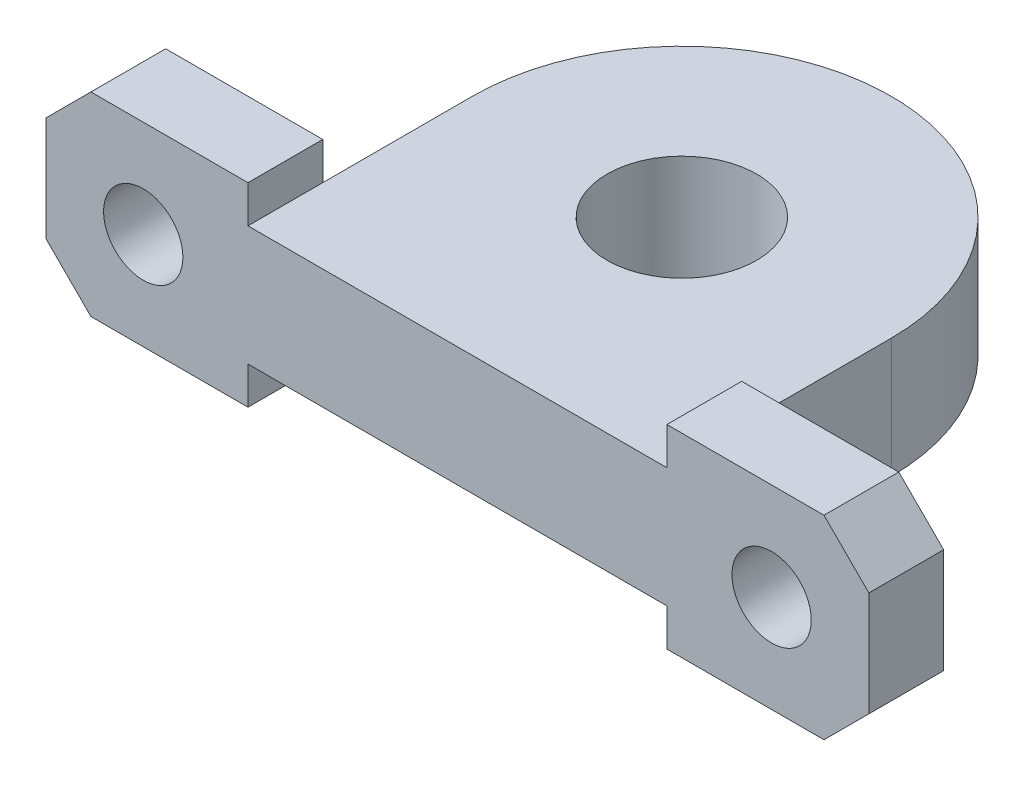
from build123d import *

# Parameters (mm, degrees)
SKETCH1_R           = 2.65
SKETCH1_W           = 1
SKETCH1_H           = 8
SKETCH1_W_2         = 14
BOSS_EXTRUDE1_DEPTH = 5
CHAMFER1_SIZE       = 3
BOSS_EXTRUDE2_DEPTH = 4
SKETCH3_R           = 5
CUT_EXTRUDE1_DEPTH  = 11.5


with BuildPart() as part:
    # Sketch1 → Boss-Extrude1 (new body)
    with BuildSketch(Plane.XY):
        Polygon((-14, -2.5), (-14, 0), (-15, 0), (-15, 8), (-14, 8), (-14, 10.5), (-27.5, 10.5), (-27.5, -2.5), align=None)
        with Locations((-21, 4)):
            Circle(SKETCH1_R, mode=Mode.SUBTRACT)
        with Locations((-14.5, 4)):
            Rectangle(SKETCH1_W, SKETCH1_H)
        with Locations((-7, 4)):
            Rectangle(SKETCH1_W_2, SKETCH1_H)
        with Locations((7, 4)):
            Rectangle(SKETCH1_W_2, SKETCH1_H)
        with Locations((14.5, 4)):
            Rectangle(SKETCH1_W, SKETCH1_H)
        Polygon((15, 8), (15, 0), (14, 0), (14, -2.5), (27.5, -2.5), (27.5, 10.5), (14, 10.5), (14, 8), align=None)
        with Locations((21, 4)):
            Circle(SKETCH1_R, mode=Mode.SUBTRACT)
    extrude(amount=BOSS_EXTRUDE1_DEPTH)

    # Chamfer1
    chamfer1_edges = [part.edges().sort_by_distance(p)[0] for p in [
        (27.5, 10.5, 2.5),
        (27.5, -2.5, 2.5),
        (-27.5, -2.5, 2.5),
        (-27.5, 10.5, 2.5),
    ]]
    chamfer(chamfer1_edges, length=CHAMFER1_SIZE)

    # Sketch2 → Boss-Extrude2 (add, symmetric)
    with BuildSketch(Plane(origin=(0, 4, 0), x_dir=(1, 0, 0), z_dir=(0, 1, 0))):
        with BuildLine():
            Line((-14, -5), (-14, 10))
            ThreePointArc((-14, 10), (0, 24), (14, 10))
            Line((14, 10), (14, -5))
            Line((14, -5), (-14, -5))
        make_face()
    extrude(amount=BOSS_EXTRUDE2_DEPTH, both=True)

    # Sketch3 → Cut-Extrude1 (cut, through all)
    with BuildSketch(Plane(origin=(0, 8, 0), x_dir=(1, 0, 0), z_dir=(0, 1, 0))):
        with Locations((0, 10)):
            Circle(SKETCH3_R)
    extrude(amount=-CUT_EXTRUDE1_DEPTH, mode=Mode.SUBTRACT)


solid = part.part
